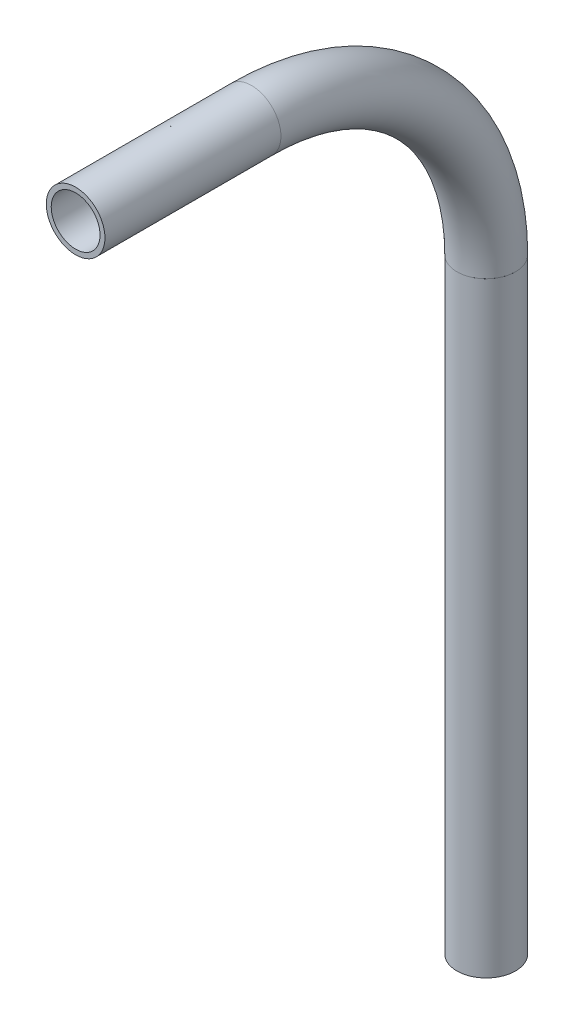
from build123d import *

# Parameters (mm, degrees)
SKETCH11_R                = 6.35
SKETCH11_R_2              = 5.2832
PIPE_0_5_SCH_40_1_DEPTH   = 131.100814919
SKETCH11_ON_SEGMENT_2_R   = 6.35
SKETCH11_ON_SEGMENT_2_R_2 = 5.2832
PIPE_0_5_SCH_40_1_2_ANGLE = 90
SKETCH11_ON_SEGMENT_3_R   = 6.35
SKETCH11_ON_SEGMENT_3_R_2 = 5.2832
PIPE_0_5_SCH_40_1_3_DEPTH = 38.1


with BuildPart() as part:
    # Sketch11 → Pipe 0.5 SCH 40(1) (new body)
    with BuildSketch(Plane(origin=(0, 1022.919021119, 296.580509383), x_dir=(0, 0, 1), z_dir=(0, 1, 0))):
        Circle(SKETCH11_R)
        Circle(SKETCH11_R_2, mode=Mode.SUBTRACT)
    extrude(amount=PIPE_0_5_SCH_40_1_DEPTH)


with BuildPart() as body_2:
    # Sketch11 on segment 2 (carried to the start of arc 2) → Pipe 0.5 SCH 40_1 2 (revolve)
    with BuildSketch(Plane(origin=(0, 1154.019836038, 296.580509383), x_dir=(0, 0, 1), z_dir=(0, 1, 0))):
        Circle(SKETCH11_ON_SEGMENT_2_R)
        Circle(SKETCH11_ON_SEGMENT_2_R_2, mode=Mode.SUBTRACT)
    revolve(axis=Axis((0, 1154.019836038, 347.380509383), (1, 0, 0)), revolution_arc=PIPE_0_5_SCH_40_1_2_ANGLE)


with BuildPart() as body_3:
    # Sketch11 on segment 3 (carried to segment 3) → Pipe 0.5 SCH 40_1 3 (new body)
    with BuildSketch(Plane(origin=(0, 1204.819836038, 385.480509383), x_dir=(0, 1, 0), z_dir=(0, 0, -1))):
        Circle(SKETCH11_ON_SEGMENT_3_R)
        Circle(SKETCH11_ON_SEGMENT_3_R_2, mode=Mode.SUBTRACT)
    extrude(amount=PIPE_0_5_SCH_40_1_3_DEPTH)


solid = Compound([part.part, body_2.part, body_3.part])
